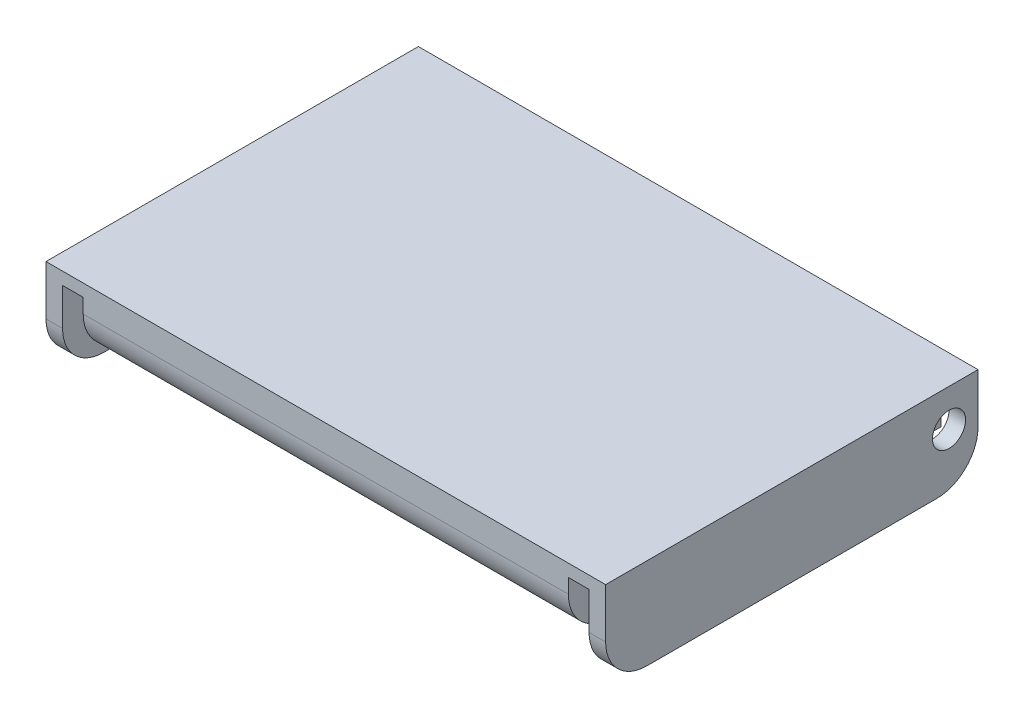
from build123d import *

# Parameters (mm, degrees)
SKETCH1_W           = 135.25
SKETCH1_H           = 90
BOSS_EXTRUDE1_DEPTH = 22
SKETCH4_W           = 5
SKETCH4_H           = 19
CUT_EXTRUDE1_DEPTH  = 91
SKETCH5_W           = 117.25
SKETCH5_H           = 11
CUT_EXTRUDE2_DEPTH  = 91
FILLET1_R           = 10
FILLET2_R           = 10
FILLET3_R           = 10
FILLET4_R           = 10
FILLET5_R           = 10
SKETCH6_R           = 4
CUT_EXTRUDE3_DEPTH  = 136.25


with BuildPart() as part:
    # Sketch1 → Boss-Extrude1 (new body)
    with BuildSketch(Plane(origin=(0, 0, 0), x_dir=(1, 0, 0), z_dir=(0, 1, 0))):
        Rectangle(SKETCH1_W, SKETCH1_H)
    extrude(amount=BOSS_EXTRUDE1_DEPTH)

    # Sketch4 → Cut-Extrude1 (cut, through all)
    with BuildSketch(Plane.XY.offset(45)):
        with Locations((-61.125, 9.5)):
            Rectangle(SKETCH4_W, SKETCH4_H)
        with Locations((61.125, 9.5)):
            Rectangle(SKETCH4_W, SKETCH4_H)
    extrude(amount=-CUT_EXTRUDE1_DEPTH, mode=Mode.SUBTRACT)

    # Sketch5 → Cut-Extrude2 (cut, through all)
    with BuildSketch(Plane(origin=(0, 0, -45), x_dir=(-1, 0, 0), z_dir=(0, 0, -1))):
        Rectangle(SKETCH5_W, SKETCH5_H)
    extrude(amount=-CUT_EXTRUDE2_DEPTH, mode=Mode.SUBTRACT)

    # Fillet1
    fillet1_edges = [part.edges().sort_by_distance(p)[0] for p in [
        (0, 5.5, 45),
    ]]
    fillet(fillet1_edges, radius=FILLET1_R)

    # Fillet2
    fillet2_edges = [part.edges().sort_by_distance(p)[0] for p in [
        (-65.625, 0, 45),
    ]]
    fillet(fillet2_edges, radius=FILLET2_R)

    # Fillet3
    fillet3_edges = [part.edges().sort_by_distance(p)[0] for p in [
        (65.625, 0, 45),
    ]]
    fillet(fillet3_edges, radius=FILLET3_R)

    # Fillet4
    fillet4_edges = [part.edges().sort_by_distance(p)[0] for p in [
        (-65.625, 0, -45),
    ]]
    fillet(fillet4_edges, radius=FILLET4_R)

    # Fillet5
    fillet5_edges = [part.edges().sort_by_distance(p)[0] for p in [
        (65.625, 0, -45),
    ]]
    fillet(fillet5_edges, radius=FILLET5_R)

    # Sketch6 → Cut-Extrude3 (cut, through all)
    with BuildSketch(Plane.ZY.offset(67.625)):
        with Locations((-38, 13)):
            Circle(SKETCH6_R)
    extrude(amount=-CUT_EXTRUDE3_DEPTH, mode=Mode.SUBTRACT)


solid = part.part
